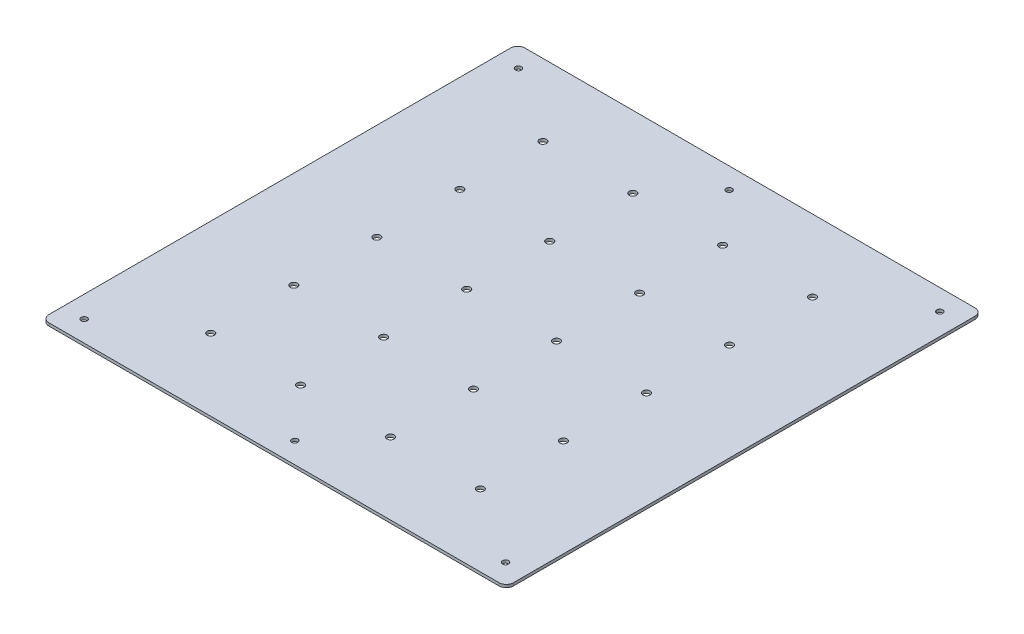
from build123d import *

# Parameters (mm, degrees)
SKETCH1_R           = 2.1
SKETCH1_R_2         = 2.5
BOSS_EXTRUDE1_DEPTH = 1


with BuildPart() as part:
    # Sketch1 → Boss-Extrude1 (new body, symmetric)
    with BuildSketch(Plane(origin=(0, 0, 0), x_dir=(1, 0, 0), z_dir=(0, 1, 0))):
        with BuildLine():
            Line((-161.5, 160.5), (-161.5, -160.5))
            ThreePointArc((-161.5, -160.5), (-160.035533906, -164.035533906), (-156.5, -165.5))
            Line((-156.5, -165.5), (156.5, -165.5))
            ThreePointArc((156.5, -165.5), (160.035533906, -164.035533906), (161.5, -160.5))
            Line((161.5, -160.5), (161.5, 160.5))
            ThreePointArc((161.5, 160.5), (160.035533906, 164.035533906), (156.5, 165.5))
            Line((156.5, 165.5), (-156.5, 165.5))
            ThreePointArc((-156.5, 165.5), (-160.035533906, 164.035533906), (-161.5, 160.5))
        make_face()
        with Locations((0, 151)):
            Circle(SKETCH1_R, mode=Mode.SUBTRACT)
        with Locations((146.5, 151)):
            Circle(SKETCH1_R, mode=Mode.SUBTRACT)
        with Locations((-146.5, 151)):
            Circle(SKETCH1_R, mode=Mode.SUBTRACT)
        with Locations((0, -151)):
            Circle(SKETCH1_R, mode=Mode.SUBTRACT)
        with Locations((146.5, -151)):
            Circle(SKETCH1_R, mode=Mode.SUBTRACT)
        with Locations((-146.5, -151)):
            Circle(SKETCH1_R, mode=Mode.SUBTRACT)
        with Locations((-94, 115.5)):
            Circle(SKETCH1_R_2, mode=Mode.SUBTRACT)
        with Locations((-31.5, 115.5)):
            Circle(SKETCH1_R_2, mode=Mode.SUBTRACT)
        with Locations((31, 115.5)):
            Circle(SKETCH1_R_2, mode=Mode.SUBTRACT)
        with Locations((93.5, 115.5)):
            Circle(SKETCH1_R_2, mode=Mode.SUBTRACT)
        with Locations((-94, 57.75)):
            Circle(SKETCH1_R_2, mode=Mode.SUBTRACT)
        with Locations((-31.5, 57.75)):
            Circle(SKETCH1_R_2, mode=Mode.SUBTRACT)
        with Locations((31, 57.75)):
            Circle(SKETCH1_R_2, mode=Mode.SUBTRACT)
        with Locations((93.5, 57.75)):
            Circle(SKETCH1_R_2, mode=Mode.SUBTRACT)
        with Locations((-94, 0)):
            Circle(SKETCH1_R_2, mode=Mode.SUBTRACT)
        with Locations((-31.5, 0)):
            Circle(SKETCH1_R_2, mode=Mode.SUBTRACT)
        with Locations((31, 0)):
            Circle(SKETCH1_R_2, mode=Mode.SUBTRACT)
        with Locations((93.5, 0)):
            Circle(SKETCH1_R_2, mode=Mode.SUBTRACT)
        with Locations((-94, -57.75)):
            Circle(SKETCH1_R_2, mode=Mode.SUBTRACT)
        with Locations((-31.5, -57.75)):
            Circle(SKETCH1_R_2, mode=Mode.SUBTRACT)
        with Locations((31, -57.75)):
            Circle(SKETCH1_R_2, mode=Mode.SUBTRACT)
        with Locations((93.5, -57.75)):
            Circle(SKETCH1_R_2, mode=Mode.SUBTRACT)
        with Locations((-94, -115.5)):
            Circle(SKETCH1_R_2, mode=Mode.SUBTRACT)
        with Locations((-31.5, -115.5)):
            Circle(SKETCH1_R_2, mode=Mode.SUBTRACT)
        with Locations((31, -115.5)):
            Circle(SKETCH1_R_2, mode=Mode.SUBTRACT)
        with Locations((93.5, -115.5)):
            Circle(SKETCH1_R_2, mode=Mode.SUBTRACT)
    extrude(amount=BOSS_EXTRUDE1_DEPTH, both=True)


solid = part.part
